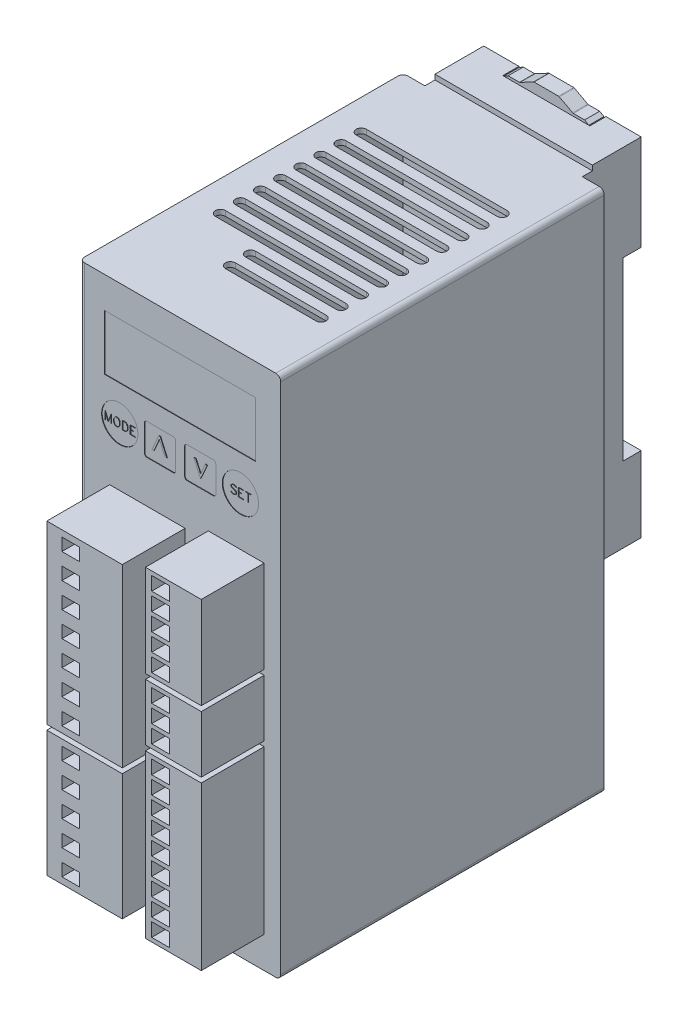
from build123d import *

# Parameters (mm, degrees)
SKETCH_1_W          = 40
SKETCH_1_H          = 104
EXTRUDE_1_DEPTH     = 64.3
SHELL_6_T           = -1
SKETCH_6_W          = 40
SKETCH_6_H          = 104
EXTRUDE_4_DEPTH     = 1
SKETCH_2_W          = 30
SKETCH_2_H          = 11
CUT_EXTRUDE_1_DEPTH = 0.1
SKETCH_3_W          = 15
SKETCH_3_H          = 35
SKETCH_3_W_2        = 3.5
SKETCH_3_H_2        = 2.5
SKETCH_3_W_3        = 11.1
SKETCH_3_H_3        = 18.3
SKETCH_3_H_4        = 2.7
SKETCH_3_H_5        = 11.3
SKETCH_3_H_6        = 32.3
EXTRUDE_3_DEPTH     = 12.5
SKETCH_4_R          = 3.6
CUT_EXTRUDE_2_DEPTH = 0.1
CUT_EXTRUDE_3_DEPTH = 1
SKETCH_9_W          = 4
SKETCH_9_H          = 7.5
CUT_EXTRUDE_4_DEPTH = 1
EXTRUDE_5_DEPTH     = 0.1
EXTRUDE_6_DEPTH     = 0.1
EXTRUDE_7_DEPTH     = 0.1
EXTRUDE_8_DEPTH     = 0.1
EXTRUDE_9_DEPTH     = 15.65
SKETCH_15_W         = 27
SKETCH_15_H         = 8.5
CUT_EXTRUDE_5_DEPTH = 5.5
SKETCH_16_W         = 6.6
SKETCH_16_H         = 2
EXTRUDE_10_DEPTH    = 2.6
CHAMFER_2_SIZE      = 1.5
SKETCH_17_W         = 15
SKETCH_17_H         = 27.946605796
CUT_EXTRUDE_6_DEPTH = 3.2
SKETCH_18_W         = 17.3
SKETCH_18_H         = 4.3
CUT_EXTRUDE_7_DEPTH = 3.2
SKETCH_19_W         = 14.6
SKETCH_19_H         = 1.5
EXTRUDE_14_DEPTH    = 3
CHAMFER_3_SIZE      = 2.5
FILLET_1_R          = 1
CUT_EXTRUDE_8_DEPTH = 8.1


with BuildPart() as part:
    # 스케치1 → 보스-돌출1 (new body)
    with BuildSketch(Plane.XY):
        with Locations((0, -40.3)):
            Rectangle(SKETCH_1_W, SKETCH_1_H)
    extrude(amount=-EXTRUDE_1_DEPTH)

    # 쉘6
    shell_6_openings = [part.faces().sort_by_distance(p)[0] for p in [
        (0, -40.3, -64.3),
    ]]
    offset(amount=SHELL_6_T, openings=shell_6_openings, kind=Kind.INTERSECTION)

    # 스케치6 → 보스-돌출4 (add)
    with BuildSketch(Plane(origin=(0, 0, -64.3), x_dir=(-1, 0, 0), z_dir=(0, 0, -1))):
        with Locations((0, -40.3)):
            Rectangle(SKETCH_6_W, SKETCH_6_H)
    extrude(amount=-EXTRUDE_4_DEPTH)

    # 스케치2 → 컷-돌출1 (cut)
    with BuildSketch(Plane.XY):
        Rectangle(SKETCH_2_W, SKETCH_2_H)
    extrude(amount=-CUT_EXTRUDE_1_DEPTH, mode=Mode.SUBTRACT)

    # 스케치3 → 보스-돌출3 (add)
    with BuildSketch(Plane.XY):
        with Locations((-6.5, -41.5)):
            Rectangle(SKETCH_3_W, SKETCH_3_H)
        with Locations((-9.25, -56.5)):
            Rectangle(SKETCH_3_W_2, SKETCH_3_H_2, mode=Mode.SUBTRACT)
        with Locations((-9.25, -51.5)):
            Rectangle(SKETCH_3_W_2, SKETCH_3_H_2, mode=Mode.SUBTRACT)
        with Locations((-9.25, -46.5)):
            Rectangle(SKETCH_3_W_2, SKETCH_3_H_2, mode=Mode.SUBTRACT)
        with Locations((-9.25, -41.5)):
            Rectangle(SKETCH_3_W_2, SKETCH_3_H_2, mode=Mode.SUBTRACT)
        with Locations((-9.25, -36.5)):
            Rectangle(SKETCH_3_W_2, SKETCH_3_H_2, mode=Mode.SUBTRACT)
        with Locations((-9.25, -31.5)):
            Rectangle(SKETCH_3_W_2, SKETCH_3_H_2, mode=Mode.SUBTRACT)
        with Locations((-9.25, -26.5)):
            Rectangle(SKETCH_3_W_2, SKETCH_3_H_2, mode=Mode.SUBTRACT)
        with Locations((11.15, -31.3)):
            Rectangle(SKETCH_3_W_3, SKETCH_3_H_3)
        with Locations((8.6, -24.3)):
            Rectangle(SKETCH_3_W_2, SKETCH_3_H_4, mode=Mode.SUBTRACT)
        with Locations((8.6, -27.8)):
            Rectangle(SKETCH_3_W_2, SKETCH_3_H_4, mode=Mode.SUBTRACT)
        with Locations((8.6, -31.3)):
            Rectangle(SKETCH_3_W_2, SKETCH_3_H_4, mode=Mode.SUBTRACT)
        with Locations((8.6, -34.8)):
            Rectangle(SKETCH_3_W_2, SKETCH_3_H_4, mode=Mode.SUBTRACT)
        with Locations((8.6, -38.3)):
            Rectangle(SKETCH_3_W_2, SKETCH_3_H_4, mode=Mode.SUBTRACT)
        with Locations((11.15, -47.1)):
            Rectangle(SKETCH_3_W_3, SKETCH_3_H_5)
        with Locations((8.6, -43.6)):
            Rectangle(SKETCH_3_W_2, SKETCH_3_H_4, mode=Mode.SUBTRACT)
        with Locations((8.6, -47.1)):
            Rectangle(SKETCH_3_W_2, SKETCH_3_H_4, mode=Mode.SUBTRACT)
        with Locations((8.6, -50.6)):
            Rectangle(SKETCH_3_W_2, SKETCH_3_H_4, mode=Mode.SUBTRACT)
        with Locations((11.15, -69.9)):
            Rectangle(SKETCH_3_W_3, SKETCH_3_H_6)
        with Locations((8.6, -55.9)):
            Rectangle(SKETCH_3_W_2, SKETCH_3_H_4, mode=Mode.SUBTRACT)
        with Locations((8.6, -59.4)):
            Rectangle(SKETCH_3_W_2, SKETCH_3_H_4, mode=Mode.SUBTRACT)
        with Locations((8.6, -62.9)):
            Rectangle(SKETCH_3_W_2, SKETCH_3_H_4, mode=Mode.SUBTRACT)
        with Locations((8.6, -66.4)):
            Rectangle(SKETCH_3_W_2, SKETCH_3_H_4, mode=Mode.SUBTRACT)
        with Locations((8.6, -69.9)):
            Rectangle(SKETCH_3_W_2, SKETCH_3_H_4, mode=Mode.SUBTRACT)
        with Locations((8.6, -73.4)):
            Rectangle(SKETCH_3_W_2, SKETCH_3_H_4, mode=Mode.SUBTRACT)
        with Locations((8.6, -76.9)):
            Rectangle(SKETCH_3_W_2, SKETCH_3_H_4, mode=Mode.SUBTRACT)
        with Locations((8.6, -80.4)):
            Rectangle(SKETCH_3_W_2, SKETCH_3_H_4, mode=Mode.SUBTRACT)
        with Locations((8.6, -83.9)):
            Rectangle(SKETCH_3_W_2, SKETCH_3_H_4, mode=Mode.SUBTRACT)
        Polygon((-14, -60), (-14, -85), (-5.1, -85), (1, -85), (1, -60), align=None)
        with Locations((-9.25, -82.5)):
            Rectangle(SKETCH_3_W_2, SKETCH_3_H_2, mode=Mode.SUBTRACT)
        with Locations((-9.25, -77.5)):
            Rectangle(SKETCH_3_W_2, SKETCH_3_H_2, mode=Mode.SUBTRACT)
        with Locations((-9.25, -72.5)):
            Rectangle(SKETCH_3_W_2, SKETCH_3_H_2, mode=Mode.SUBTRACT)
        with Locations((-9.25, -67.5)):
            Rectangle(SKETCH_3_W_2, SKETCH_3_H_2, mode=Mode.SUBTRACT)
        with Locations((-9.25, -62.5)):
            Rectangle(SKETCH_3_W_2, SKETCH_3_H_2, mode=Mode.SUBTRACT)
    extrude(amount=EXTRUDE_3_DEPTH)

    # 스케치4 → 컷-돌출2 (cut)
    with BuildSketch(Plane.XY):
        with Locations((-12, -12.5)):
            Circle(SKETCH_4_R)
        with Locations((12, -12.5)):
            Circle(SKETCH_4_R)
        with BuildLine():
            Line((-6.6, -15.6), (-1.4, -15.6))
            ThreePointArc((-1.4, -15.6), (-1.046446609, -15.453553391), (-0.9, -15.1))
            Line((-0.9, -15.1), (-0.9, -9.9))
            ThreePointArc((-0.9, -9.9), (-1.046446609, -9.546446609), (-1.4, -9.4))
            Line((-1.4, -9.4), (-6.6, -9.4))
            ThreePointArc((-6.6, -9.4), (-6.953553391, -9.546446609), (-7.1, -9.9))
            Line((-7.1, -9.9), (-7.1, -15.1))
            ThreePointArc((-7.1, -15.1), (-6.953553391, -15.453553391), (-6.6, -15.6))
        make_face()
        with BuildLine():
            Line((7.1, -9.9), (7.1, -15.1))
            ThreePointArc((7.1, -15.1), (6.953553391, -15.453553391), (6.6, -15.6))
            Line((6.6, -15.6), (1.4, -15.6))
            ThreePointArc((1.4, -15.6), (1.046446609, -15.453553391), (0.9, -15.1))
            Line((0.9, -15.1), (0.9, -9.9))
            ThreePointArc((0.9, -9.9), (1.046446609, -9.546446609), (1.4, -9.4))
            Line((1.4, -9.4), (6.6, -9.4))
            ThreePointArc((6.6, -9.4), (6.953553391, -9.546446609), (7.1, -9.9))
        make_face()
    extrude(amount=-CUT_EXTRUDE_2_DEPTH, mode=Mode.SUBTRACT)

    # 스케치7 → 컷-돌출3 (cut)
    with BuildSketch(Plane(origin=(0, 11.7, 0), x_dir=(1, 0, 0), z_dir=(0, 1, 0))):
        with BuildLine():
            Line((14, 15), (-4, 15))
            ThreePointArc((-4, 15), (-5, 14), (-4, 13))
            Line((-4, 13), (14, 13))
            ThreePointArc((14, 13), (15, 14), (14, 15))
        make_face()
        with BuildLine():
            Line((14, 19), (-4, 19))
            ThreePointArc((-4, 19), (-5, 18), (-4, 17))
            Line((-4, 17), (14, 17))
            ThreePointArc((14, 17), (15, 18), (14, 19))
        make_face()
        with BuildLine():
            Line((14, 23), (-14, 23))
            ThreePointArc((-14, 23), (-15, 22), (-14, 21))
            Line((-14, 21), (14, 21))
            ThreePointArc((14, 21), (15, 22), (14, 23))
        make_face()
        with BuildLine():
            Line((14, 27), (-14, 27))
            ThreePointArc((-14, 27), (-15, 26), (-14, 25))
            Line((-14, 25), (14, 25))
            ThreePointArc((14, 25), (15, 26), (14, 27))
        make_face()
        with BuildLine():
            Line((14, 31), (-14, 31))
            ThreePointArc((-14, 31), (-15, 30), (-14, 29))
            Line((-14, 29), (14, 29))
            ThreePointArc((14, 29), (15, 30), (14, 31))
        make_face()
        with BuildLine():
            Line((14, 35), (-14, 35))
            ThreePointArc((-14, 35), (-15, 34), (-14, 33))
            Line((-14, 33), (14, 33))
            ThreePointArc((14, 33), (15, 34), (14, 35))
        make_face()
        with BuildLine():
            Line((14, 39), (-14, 39))
            ThreePointArc((-14, 39), (-15, 38), (-14, 37))
            Line((-14, 37), (14, 37))
            ThreePointArc((14, 37), (15, 38), (14, 39))
        make_face()
        with BuildLine():
            Line((14, 43), (-14, 43))
            ThreePointArc((-14, 43), (-15, 42), (-14, 41))
            Line((-14, 41), (14, 41))
            ThreePointArc((14, 41), (15, 42), (14, 43))
        make_face()
        with BuildLine():
            Line((14, 47), (-14, 47))
            ThreePointArc((-14, 47), (-15, 46), (-14, 45))
            Line((-14, 45), (14, 45))
            ThreePointArc((14, 45), (15, 46), (14, 47))
        make_face()
        with BuildLine():
            Line((14, 51), (-14, 51))
            ThreePointArc((-14, 51), (-15, 50), (-14, 49))
            Line((-14, 49), (14, 49))
            ThreePointArc((14, 49), (15, 50), (14, 51))
        make_face()
    extrude(amount=-CUT_EXTRUDE_3_DEPTH, mode=Mode.SUBTRACT)

    # 스케치9 → 컷-돌출4 (cut)
    with BuildSketch(Plane.XZ.offset(92.3)):
        with BuildLine():
            Line((4, -49), (-4, -49))
            ThreePointArc((-4, -49), (-5, -50), (-4, -51))
            Line((-4, -51), (4, -51))
            ThreePointArc((4, -51), (5, -50), (4, -49))
        make_face()
        with BuildLine():
            Line((4, -45), (-4, -45))
            ThreePointArc((-4, -45), (-5, -46), (-4, -47))
            Line((-4, -47), (4, -47))
            ThreePointArc((4, -47), (5, -46), (4, -45))
        make_face()
        with BuildLine():
            Line((4, -41), (-4, -41))
            ThreePointArc((-4, -41), (-5, -42), (-4, -43))
            Line((-4, -43), (4, -43))
            ThreePointArc((4, -43), (5, -42), (4, -41))
        make_face()
        with BuildLine():
            Line((14, -37), (-4, -37))
            ThreePointArc((-4, -37), (-5, -38), (-4, -39))
            Line((-4, -39), (14, -39))
            ThreePointArc((14, -39), (15, -38), (14, -37))
        make_face()
        with BuildLine():
            Line((14, -33), (-4, -33))
            ThreePointArc((-4, -33), (-5, -34), (-4, -35))
            Line((-4, -35), (14, -35))
            ThreePointArc((14, -35), (15, -34), (14, -33))
        make_face()
        with BuildLine():
            Line((14, -29), (-4, -29))
            ThreePointArc((-4, -29), (-5, -30), (-4, -31))
            Line((-4, -31), (14, -31))
            ThreePointArc((14, -31), (15, -30), (14, -29))
        make_face()
        with BuildLine():
            Line((14, -25), (-4, -25))
            ThreePointArc((-4, -25), (-5, -26), (-4, -27))
            Line((-4, -27), (14, -27))
            ThreePointArc((14, -27), (15, -26), (14, -25))
        make_face()
        with BuildLine():
            Line((14, -21), (-4, -21))
            ThreePointArc((-4, -21), (-5, -22), (-4, -23))
            Line((-4, -23), (14, -23))
            ThreePointArc((14, -23), (15, -22), (14, -21))
        make_face()
        with BuildLine():
            Line((14, -17), (-4, -17))
            ThreePointArc((-4, -17), (-5, -18), (-4, -19))
            Line((-4, -19), (14, -19))
            ThreePointArc((14, -19), (15, -18), (14, -17))
        make_face()
        with BuildLine():
            Line((14, -13), (-4, -13))
            ThreePointArc((-4, -13), (-5, -14), (-4, -15))
            Line((-4, -15), (14, -15))
            ThreePointArc((14, -15), (15, -14), (14, -13))
        make_face()
        with Locations((10.5, -43.75)):
            Rectangle(SKETCH_9_W, SKETCH_9_H)
    extrude(amount=-CUT_EXTRUDE_4_DEPTH, mode=Mode.SUBTRACT)

    # 스케치10 → 보스-돌출5 (add)
    with BuildSketch(Plane.XY.offset(-0.1)):
        Polygon((-13.727758591, -13.315706685), (-13.761359719, -13.315706685), (-13.761359719, -11.831656852), (-14.328223199, -13.315706685), (-14.364002178, -13.315706685), (-14.932110143, -11.831656852), (-14.932110143, -13.315706685), (-14.965711272, -13.315706685), (-14.965711272, -11.722764306), (-14.93739921, -11.722764306), (-14.346268249, -13.26872733), (-13.756070653, -11.722764306), (-13.727758591, -11.722764306), align=None)
        Polygon((-12.010056467, -12.720220022), (-12.087836857, -12.950138854), (-12.163439396, -13.105699633), (-12.317755689, -13.260015926), (-12.475183197, -13.335618465), (-12.785060269, -13.335618465), (-12.941554413, -13.260015926), (-13.096804071, -13.105699633), (-13.171473245, -12.950138854), (-13.249253634, -12.720220022), (-13.249253634, -12.340029478), (-13.171473245, -12.110110646), (-13.096804071, -11.954860989), (-12.941554413, -11.800544696), (-12.785060269, -11.722764306), (-12.475183197, -11.722764306), (-12.317755689, -11.800544696), (-12.163439396, -11.954860989), (-12.087836857, -12.110110646), (-12.010056467, -12.340029478), align=None)
        Polygon((-12.044902082, -12.710886376), (-12.044902082, -12.339096113), (-12.11832677, -12.117577564), (-12.192995944, -11.971661553), (-12.339845319, -11.824501056), (-12.483583479, -11.752320854), (-12.775726623, -11.752320854), (-12.920398147, -11.824501056), (-13.06662528, -11.971661553), (-13.142227818, -12.117577564), (-13.21440802, -12.339096113), (-13.21440802, -12.710886376), (-13.142227818, -12.932404925), (-13.06662528, -13.078320936), (-12.920398147, -13.225481433), (-12.775726623, -13.297972756), (-12.483583479, -13.297972756), (-12.339845319, -13.225481433), (-12.192995944, -13.078320936), (-12.11832677, -12.932404925), align=None, mode=Mode.SUBTRACT)
        Polygon((-10.432981288, -12.720220022), (-10.510761678, -12.950138854), (-10.585430852, -13.105699633), (-10.74285836, -13.260015926), (-10.974955043, -13.335618465), (-11.520973378, -13.335618465), (-11.520973378, -11.722764306), (-10.974955043, -11.722764306), (-10.74285836, -11.800544696), (-10.585430852, -11.954860989), (-10.510761678, -12.110110646), (-10.432981288, -12.340029478), align=None)
        Polygon((-10.467826903, -12.710886376), (-10.467826903, -12.339096113), (-10.540318226, -12.117577564), (-10.615920765, -11.971661553), (-10.759658924, -11.824501056), (-10.978999623, -11.752320854), (-11.487372249, -11.752320854), (-11.487372249, -13.297972756), (-10.978999623, -13.297972756), (-10.759658924, -13.225481433), (-10.615920765, -13.078320936), (-10.540318226, -12.932404925), align=None, mode=Mode.SUBTRACT)
        Polygon((-8.952353792, -13.335618465), (-9.947942779, -13.335618465), (-9.947942779, -11.722764306), (-8.952353792, -11.722764306), (-8.952353792, -11.757298799), (-9.91434165, -11.757298799), (-9.91434165, -12.475678477), (-9.328499756, -12.475678477), (-9.328499756, -12.51021297), (-9.91434165, -12.51021297), (-9.91434165, -13.302950701), (-8.952353792, -13.302950701), align=None)
    extrude(amount=EXTRUDE_5_DEPTH)

    # 스케치11 → 보스-돌출6 (add)
    with BuildSketch(Plane.XY.offset(-0.1)):
        Polygon((11.144023777, -13.094479141), (10.984418418, -13.253151136), (10.752321735, -13.328753675), (10.446800365, -13.328753675), (10.214703683, -13.253151136), (10.06038739, -13.101012694), (10.085588236, -13.074567362), (10.232437611, -13.223594588), (10.452089432, -13.296085911), (10.747966034, -13.296085911), (10.967617854, -13.223594588), (11.109178163, -13.080789793), (11.109178163, -12.866738161), (11.03668684, -12.721755514), (10.965440003, -12.651442042), (10.819523992, -12.575839504), (10.368086611, -12.425567791), (10.212525832, -12.349965252), (10.132878713, -12.270318133), (10.056031688, -12.113823989), (10.056031688, -11.952040779), (10.214703683, -11.793679906), (10.446800365, -11.715899516), (10.752321735, -11.715899516), (10.984418418, -11.793679906), (11.139668076, -11.945818348), (11.113533865, -11.971952559), (10.967617854, -11.822925332), (10.747966034, -11.750434009), (10.452089432, -11.750434009), (10.232437611, -11.822925332), (10.089632816, -11.965730128), (10.089632816, -12.105423707), (10.163057504, -12.249161867), (10.234615462, -12.319786461), (10.380531473, -12.395389), (10.831968854, -12.545349591), (10.987529634, -12.620952129), (11.066243388, -12.70091037), (11.144023777, -12.857404514), align=None)
        Polygon((12.545004155, -13.328753675), (11.549415168, -13.328753675), (11.549415168, -11.715899516), (12.545004155, -11.715899516), (12.545004155, -11.750434009), (11.583016296, -11.750434009), (11.583016296, -12.468813687), (12.168858191, -12.468813687), (12.168858191, -12.50334818), (11.583016296, -12.50334818), (11.583016296, -13.296085911), (12.545004155, -13.296085911), align=None)
        Polygon((14.034343054, -11.750434009), (13.523792577, -11.750434009), (13.523792577, -13.308841895), (13.489258084, -13.308841895), (13.489258084, -11.750434009), (12.979952093, -11.750434009), (12.979952093, -11.715899516), (14.034343054, -11.715899516), align=None)
    extrude(amount=EXTRUDE_6_DEPTH)

    # 스케치12 → 보스-돌출7 (add)
    with BuildSketch(Plane.XY.offset(-0.1)):
        Polygon((-4.262423248, -10.710950186), (-3.957134786, -10.710950186), (-2.634218119, -13.712953391), (-3.018213762, -13.712953391), (-4.109779017, -11.236459751), (-5.201344271, -13.712953391), (-5.585339914, -13.712953391), align=None)
    extrude(amount=EXTRUDE_7_DEPTH)

    # 스케치13 → 보스-돌출8 (add)
    with BuildSketch(Plane.XY.offset(-0.1)):
        Polygon((2.709868569, -10.967782947), (3.095454256, -10.967782947), (4.058225941, -13.079361472), (5.020997626, -10.967782947), (5.406583313, -10.967782947), (4.083666646, -13.868023331), (4.032785236, -13.868023331), align=None)
    extrude(amount=EXTRUDE_8_DEPTH)

    # 스케치14 → 보스-돌출9 (add, symmetric)
    with BuildSketch(Plane(origin=(0, 0, 0), x_dir=(0, 0, -1), z_dir=(1, 0, 0))):
        Polygon((66.3, 12.7), (66.3, 11.7), (64.3, 11.7), (64.3, -55.3), (66.3, -55.3), (66.3, -56.3), (76, -56.3), (76, -41.3), (72.4, -41.3), (72.4, -6.3), (76, -6.3), (76, 12.7), align=None)
    extrude(amount=EXTRUDE_9_DEPTH, both=True)

    # 스케치15 → 컷-돌출5 (cut)
    with BuildSketch(Plane(origin=(0, 0, -76), x_dir=(-1, 0, 0), z_dir=(0, 0, -1))):
        with Locations((0, -50.05)):
            Rectangle(SKETCH_15_W, SKETCH_15_H)
    extrude(amount=-CUT_EXTRUDE_5_DEPTH, mode=Mode.SUBTRACT)

    # 스케치16 → 보스-돌출10 (add)
    with BuildSketch(Plane(origin=(0, 0, -76), x_dir=(-1, 0, 0), z_dir=(0, 0, -1))):
        with Locations((-8.3, -40.3)):
            Rectangle(SKETCH_16_W, SKETCH_16_H)
        with Locations((8.3, -40.3)):
            Rectangle(SKETCH_16_W, SKETCH_16_H)
    extrude(amount=-EXTRUDE_10_DEPTH)

    # 모따기2
    chamfer_2_edges = [part.edges().sort_by_distance(p)[0] for p in [
        (8.3, -39.3, -76),
        (-8.3, -39.3, -76),
    ]]
    chamfer(chamfer_2_edges, length=CHAMFER_2_SIZE)

    # 스케치17 → 컷-돌출6 (cut)
    with BuildSketch(Plane(origin=(0, 0, -76), x_dir=(-1, 0, 0), z_dir=(0, 0, -1))):
        with Locations((0, 3.119908693)):
            Rectangle(SKETCH_17_W, SKETCH_17_H)
    extrude(amount=-CUT_EXTRUDE_6_DEPTH, mode=Mode.SUBTRACT)

    # 스케치18 → 컷-돌출7 (cut)
    with BuildSketch(Plane(origin=(0, 0, -76), x_dir=(-1, 0, 0), z_dir=(0, 0, -1))):
        with Locations((0, 12.55)):
            Rectangle(SKETCH_18_W, SKETCH_18_H)
    extrude(amount=-CUT_EXTRUDE_7_DEPTH, mode=Mode.SUBTRACT)

    # 스케치19 → 보스-돌출14 (add)
    with BuildSketch(Plane(origin=(0, 0, -72.8), x_dir=(-1, 0, 0), z_dir=(0, 0, -1))):
        with Locations((0, -7.05)):
            Rectangle(SKETCH_19_W, SKETCH_19_H)
        Polygon((8.45, 12.7), (-8.45, 12.7), (-8.45, 10.6), (-7.3, 10.6), (-7.3, -6.3), (7.3, -6.3), (7.3, 10.6), (8.45, 10.6), align=None)
        with BuildLine():
            Line((-5.375295207, 13.2), (-7.6, 13.2))
            Line((-7.6, 13.2), (-8.45, 12.7))
            Line((-8.45, 12.7), (8.45, 12.7))
            Line((8.45, 12.7), (7.6, 13.2))
            Line((7.6, 13.2), (5.375295207, 13.2))
            ThreePointArc((5.375295207, 13.2), (5.302265067, 13.209024746), (5.233628783, 13.235556009))
            Line((5.233628783, 13.235556009), (2.566371217, 14.664443991))
            ThreePointArc((2.566371217, 14.664443991), (2.497734933, 14.690975254), (2.424704793, 14.7))
            Line((2.424704793, 14.7), (-2.424704793, 14.7))
            ThreePointArc((-2.424704793, 14.7), (-2.497734933, 14.690975254), (-2.566371217, 14.664443991))
            Line((-2.566371217, 14.664443991), (-5.233628783, 13.235556009))
            ThreePointArc((-5.233628783, 13.235556009), (-5.302265067, 13.209024746), (-5.375295207, 13.2))
        make_face()
    extrude(amount=EXTRUDE_14_DEPTH)

    # 모따기3
    chamfer_3_edges = [part.edges().sort_by_distance(p)[0] for p in [
        (0, -7.8, -75.8),
    ]]
    chamfer(chamfer_3_edges, length=CHAMFER_3_SIZE)

    # 필렛1
    fillet_1_edges = [part.edges().sort_by_distance(p)[0] for p in [
        (-20, -40.3, -64.3),
        (-20, -40.3, 0),
        (20, -92.3, -32.15),
        (19, -40.3, -1),
        (20, 11.7, -32.15),
    ]]
    fillet(fillet_1_edges, radius=FILLET_1_R)

    # 스케치20 → 컷-돌출8 (cut)
    with BuildSketch(Plane(origin=(0, 0, -72.4), x_dir=(-1, 0, 0), z_dir=(0, 0, -1))):
        with BuildLine():
            Line((1.5, -17.3), (1.5, -26.3))
            ThreePointArc((1.5, -26.3), (0, -27.8), (-1.5, -26.3))
            Line((-1.5, -26.3), (-1.5, -17.3))
            ThreePointArc((-1.5, -17.3), (0, -15.8), (1.5, -17.3))
        make_face()
    extrude(amount=-CUT_EXTRUDE_8_DEPTH, mode=Mode.SUBTRACT)


solid = part.part
